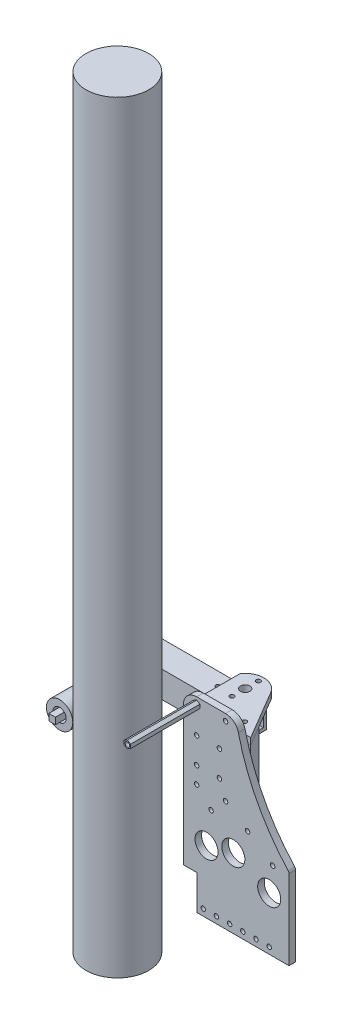
from build123d import *

# Parameters (mm, degrees)
ELEVATION_BAR_R            = 30.226
ELEVATION_BAR_PART_DEPTH   = 734.06
CLAMP_GEO_R                = 4.7625
CLAMP_GEO_W                = 6.35
CLAMP_GEO_H                = 12.7
CLAMP_GEO_R_2              = 1.8288
BOSS_EXTRUDE1_DEPTH        = 12.7
BOSS_EXTRUDE1_DEPTH_BACK   = 12.7
SKETCH2_W                  = 19.05
SKETCH2_H                  = 19.05
CUT_EXTRUDE2_DEPTH         = 105.590945
SKETCH3_R                  = 4.544009597
CUT_EXTRUDE3_DEPTH         = 25.4
CLAMP_GEO_3_W              = 6.35
CLAMP_GEO_3_H              = 81.75625
CLAMP_GEO_3_H_2            = 12.7
CLAMP_GEO_3_R              = 1.8288
BOSS_EXTRUDE2_DEPTH        = 3.175
BOSS_EXTRUDE2_DEPTH_BACK   = 3.175
CUSTOM_DRIVEN_FLYWHEEL_R   = 12.7
CUSTOM_DRIVEN_FLYWHEEL_R_2 = 6.35
BOSS_EXTRUDE3_DEPTH        = 12.7
BOSS_EXTRUDE3_DEPTH_BACK   = 25.4
SKETCH8_W                  = 12.7
SKETCH8_H                  = 18.542
SKETCH8_R                  = 1.8288
BOSS_EXTRUDE5_DEPTH        = 9.525
SKETCH10_W                 = 6.35
SKETCH10_H                 = 18.542
SKETCH10_R                 = 1.8288
CUT_EXTRUDE5_DEPTH         = 3.175
SKETCH17_R                 = 11.1125
SKETCH17_R_2               = 2.15265
BOSS_EXTRUDE6_DEPTH        = 6.35
SKETCH19_R                 = 2.15265
CUT_EXTRUDE6_DEPTH         = 36.5125
SKETCH23_R                 = 2.15265
SKETCH23_R_2               = 4.5466
BOSS_EXTRUDE7_DEPTH        = 6.35
SKETCH25_R                 = 2.15265
BOSS_EXTRUDE8_DEPTH        = 47.879
SKETCH26_R                 = 2.15265
CUT_EXTRUDE8_DEPTH         = 26.933555
SKETCH27_R                 = 2.15265
BOSS_EXTRUDE9_DEPTH        = 66.675
SKETCH28_R                 = 2.15265
BOSS_EXTRUDE10_DEPTH       = 4.8006
SKETCH31_R                 = 2.15265
CUT_EXTRUDE9_DEPTH         = 25.4
SKETCH33_R                 = 2.15265
CUT_EXTRUDE10_DEPTH        = 25.4


with BuildPart() as part:
    # Elevation Bar → Elevation Bar Part (new body)
    with BuildSketch(Plane(origin=(0, 0, 0), x_dir=(1, 0, 0), z_dir=(0, 1, 0))):
        Circle(ELEVATION_BAR_R)
    extrude(amount=ELEVATION_BAR_PART_DEPTH)


with BuildPart() as body_2:
    # Clamp Geo → Boss-Extrude1 (new body, two sides)
    with BuildSketch(Plane(origin=(0, 182.88, 0), x_dir=(1, 0, 0), z_dir=(0, 1, 0))) as boss_extrude1_sk:
        Polygon((39.751, 61.9125), (56.314945047, 61.9125), (56.314945047, 87.3125), (-39.751, 87.3125), (-39.751, 74.6125), (-39.751, 61.9125), (33.401, 61.9125), align=None)
        with Locations((48.377445047, 74.6125)):
            Circle(CLAMP_GEO_R, mode=Mode.SUBTRACT)
        Polygon((-46.101, 74.6125), (-46.101, 87.3125), (-49.276, 87.3125), (-49.276, 61.9125), (-46.101, 61.9125), align=None)
        with Locations((-42.926, 68.2625)):
            Rectangle(CLAMP_GEO_W, CLAMP_GEO_H)
        with Locations((-42.926, 68.2625)):
            Circle(CLAMP_GEO_R_2, mode=Mode.SUBTRACT)
        with Locations((-42.926, 80.9625)):
            Rectangle(CLAMP_GEO_W, CLAMP_GEO_H)
        with Locations((-42.926, 80.9625)):
            Circle(CLAMP_GEO_R_2, mode=Mode.SUBTRACT)
    extrude(amount=BOSS_EXTRUDE1_DEPTH)
    extrude(boss_extrude1_sk.sketch, amount=-BOSS_EXTRUDE1_DEPTH_BACK)

    # Sketch2 → Cut-Extrude2 (cut)
    with BuildSketch(Plane.ZY.offset(49.276)):
        with Locations((-74.6125, 182.88)):
            Rectangle(SKETCH2_W, SKETCH2_H)
    extrude(amount=-CUT_EXTRUDE2_DEPTH, mode=Mode.SUBTRACT)

    # Sketch3 → Cut-Extrude3 (cut)
    with BuildSketch(Plane(origin=(0, 0, -87.3125), x_dir=(-1, 0, 0), z_dir=(0, 0, -1))):
        with Locations((42.926, 182.88)):
            Circle(SKETCH3_R)
    extrude(amount=-CUT_EXTRUDE3_DEPTH, mode=Mode.SUBTRACT)

    # Sketch31 → Cut-Extrude9 (cut)
    with BuildSketch(Plane.XY.offset(-61.9125)):
        with Locations((36.576, 182.88)):
            Circle(SKETCH31_R)
    extrude(amount=-CUT_EXTRUDE9_DEPTH, mode=Mode.SUBTRACT)

    # Sketch33 → Cut-Extrude10 (cut)
    with BuildSketch(Plane.XZ.offset(-170.18)):
        with Locations((22.195724324, -74.6125)):
            Circle(SKETCH33_R)
    extrude(amount=-CUT_EXTRUDE10_DEPTH, mode=Mode.SUBTRACT)


with BuildPart() as body_3:
    # Clamp Geo_3 → Boss-Extrude2 (new body, two sides)
    with BuildSketch(Plane(origin=(0, 182.88, 0), x_dir=(1, 0, 0), z_dir=(0, 1, 0))) as boss_extrude2_sk:
        with Locations((-42.926, 21.034375)):
            Rectangle(CLAMP_GEO_3_W, CLAMP_GEO_3_H)
        with Locations((-42.926, 68.2625)):
            Rectangle(CLAMP_GEO_3_W, CLAMP_GEO_3_H_2)
        with Locations((-42.926, 68.2625)):
            Circle(CLAMP_GEO_3_R, mode=Mode.SUBTRACT)
        with Locations((-42.926, 80.9625)):
            Rectangle(CLAMP_GEO_3_W, CLAMP_GEO_3_H_2)
        with Locations((-42.926, 80.9625)):
            Circle(CLAMP_GEO_3_R, mode=Mode.SUBTRACT)
    extrude(amount=BOSS_EXTRUDE2_DEPTH)
    extrude(boss_extrude2_sk.sketch, amount=-BOSS_EXTRUDE2_DEPTH_BACK)


with BuildPart() as body_4:
    # Custom Driven Flywheel → Boss-Extrude3 (new body, two sides)
    with BuildSketch(Plane.XY) as boss_extrude3_sk:
        with Locations((-42.926, 182.88)):
            Circle(CUSTOM_DRIVEN_FLYWHEEL_R)
        with Locations((-42.926, 182.88)):
            Circle(CUSTOM_DRIVEN_FLYWHEEL_R_2, mode=Mode.SUBTRACT)
    extrude(amount=BOSS_EXTRUDE3_DEPTH)
    extrude(boss_extrude3_sk.sketch, amount=-BOSS_EXTRUDE3_DEPTH_BACK)


with BuildPart() as body_5:
    # Sketch8 → Boss-Extrude5 (new body)
    with BuildSketch(Plane(origin=(0, 173.355, 0), x_dir=(1, 0, 0), z_dir=(0, 1, 0))):
        with Locations((-42.926, 74.6125)):
            Rectangle(SKETCH8_W, SKETCH8_H)
        with Locations((-42.926, 80.9625)):
            Circle(SKETCH8_R, mode=Mode.SUBTRACT)
        with Locations((-42.926, 68.2625)):
            Circle(SKETCH8_R, mode=Mode.SUBTRACT)
    extrude(amount=BOSS_EXTRUDE5_DEPTH)

    # Sketch10 → Cut-Extrude5 (cut)
    with BuildSketch(Plane(origin=(0, 182.88, 0), x_dir=(1, 0, 0), z_dir=(0, 1, 0))):
        with Locations((-42.926, 74.6125)):
            Rectangle(SKETCH10_W, SKETCH10_H)
        with Locations((-42.926, 68.2625)):
            Circle(SKETCH10_R, mode=Mode.SUBTRACT)
        with Locations((-42.926, 80.9625)):
            Circle(SKETCH10_R, mode=Mode.SUBTRACT)
    extrude(amount=-CUT_EXTRUDE5_DEPTH, mode=Mode.SUBTRACT)


with BuildPart() as body_6:
    # Sketch17 → Boss-Extrude6 (new body)
    with BuildSketch(Plane.XY.offset(-36.5125)):
        with BuildLine():
            Line((135.001, 118.017245545), (135.001, 73.152))
            Line((135.001, 73.152), (135.001, 41.275))
            Line((135.001, 41.275), (46.355, 41.275))
            Line((46.355, 41.275), (46.355, 74.6125))
            Line((46.355, 74.6125), (33.401, 74.6125))
            Line((33.401, 74.6125), (33.401, 208.28))
            ThreePointArc((33.401, 208.28), (37.120743879, 217.260256121), (46.101, 220.98))
            Line((46.101, 220.98), (73.935512876, 220.98))
            ThreePointArc((73.935512876, 220.98), (81.833694908, 218.22528635), (86.30554153, 211.156176471))
            ThreePointArc((86.30554153, 211.156176471), (104.387300681, 162.579639504), (134.170615385, 120.158134075))
            ThreePointArc((134.170615385, 120.158134075), (134.786133345, 119.165389951), (135.001, 118.017245545))
        make_face()
        with Locations((55.626, 101.727)):
            Circle(SKETCH17_R, mode=Mode.SUBTRACT)
        with Locations((81.409159883, 108.54737876)):
            Circle(SKETCH17_R, mode=Mode.SUBTRACT)
        with Locations((115.951, 92.470336702)):
            Circle(SKETCH17_R, mode=Mode.SUBTRACT)
        with Locations((46.101, 214.63)):
            Circle(SKETCH17_R_2, mode=Mode.SUBTRACT)
        with Locations((73.935512876, 214.63)):
            Circle(SKETCH17_R_2, mode=Mode.SUBTRACT)
        with Locations((119.286745244, 116.882770029)):
            Circle(SKETCH17_R_2, mode=Mode.SUBTRACT)
        with Locations((46.101, 147.955)):
            Circle(SKETCH17_R_2, mode=Mode.SUBTRACT)
        with Locations((73.935512876, 147.955)):
            Circle(SKETCH17_R_2, mode=Mode.SUBTRACT)
        with Locations((60.018256438, 133.455471594)):
            Circle(SKETCH17_R_2, mode=Mode.SUBTRACT)
        with Locations((95.098187154, 133.455471594)):
            Circle(SKETCH17_R_2, mode=Mode.SUBTRACT)
    extrude(amount=BOSS_EXTRUDE6_DEPTH)

    # Sketch19 → Cut-Extrude6 (cut)
    with BuildSketch(Plane.XY):
        with Locations((39.751, 47.625)):
            Circle(SKETCH19_R)
        with Locations((52.451, 47.625)):
            Circle(SKETCH19_R)
        with Locations((65.151, 47.625)):
            Circle(SKETCH19_R)
        with Locations((77.851, 47.625)):
            Circle(SKETCH19_R)
        with Locations((90.551, 47.625)):
            Circle(SKETCH19_R)
        with Locations((103.251, 47.625)):
            Circle(SKETCH19_R)
        with Locations((115.951, 47.625)):
            Circle(SKETCH19_R)
    extrude(amount=-CUT_EXTRUDE6_DEPTH, mode=Mode.SUBTRACT)


with BuildPart() as body_7:
    # Sketch23 → Boss-Extrude7 (new body)
    with BuildSketch(Plane(origin=(0, 200.3425, 0), x_dir=(1, 0, 0), z_dir=(0, 1, 0))):
        with BuildLine():
            ThreePointArc((63.899351564, 83.78128305), (57.983234825, 59.357174134), (33.401, 64.577448517))
            Line((33.401, 64.577448517), (33.401, 36.5125))
            Line((33.401, 36.5125), (91.821, 36.5125))
            Line((91.821, 36.5125), (63.899351564, 83.78128305))
        make_face()
        with Locations((56.531651772, 46.804277476)):
            Circle(SKETCH23_R, mode=Mode.SUBTRACT)
        with Locations((75.581651772, 46.804277476)):
            Circle(SKETCH23_R, mode=Mode.SUBTRACT)
        with BuildLine():
            ThreePointArc((63.899351564, 83.78128305), (48.889292, 92.632882272), (33.401, 84.647551483))
            Line((33.401, 84.647551483), (33.401, 64.577448517))
            ThreePointArc((33.401, 64.577448517), (57.983234825, 59.357174134), (63.899351564, 83.78128305))
        make_face()
        with Locations((48.377445047, 61.9125)):
            Circle(SKETCH23_R, mode=Mode.SUBTRACT)
        with Locations((48.377445047, 74.6125)):
            Circle(SKETCH23_R_2, mode=Mode.SUBTRACT)
        with Locations((48.377445047, 87.3125)):
            Circle(SKETCH23_R, mode=Mode.SUBTRACT)
    extrude(amount=BOSS_EXTRUDE7_DEPTH)


with BuildPart() as body_8:
    # Sketch25 → Boss-Extrude8 (new body)
    with BuildSketch(Plane.XZ.offset(-200.3425)):
        with BuildLine():
            Line((91.821, -36.5125), (80.399595356, -55.847887718))
            ThreePointArc((80.399595356, -55.847887718), (79.471677579, -56.762053052), (78.212641285, -57.096054953))
            Line((78.212641285, -57.096054953), (35.941, -57.096054953))
            ThreePointArc((35.941, -57.096054953), (34.144948776, -56.352106177), (33.401, -54.556054953))
            Line((33.401, -54.556054953), (33.401, -36.5125))
            Line((33.401, -36.5125), (91.821, -36.5125))
        make_face()
        with Locations((56.531651772, -46.804277476)):
            Circle(SKETCH25_R, mode=Mode.SUBTRACT)
        with Locations((75.581651772, -46.804277476)):
            Circle(SKETCH25_R, mode=Mode.SUBTRACT)
    extrude(amount=BOSS_EXTRUDE8_DEPTH)


with BuildPart() as cut_extrude8_tool:
    # Sketch26 → Cut-Extrude8 (new body)
    with BuildSketch(Plane(origin=(0, 0, -57.096054953), x_dir=(-1, 0, 0), z_dir=(0, 0, -1))):
        with Locations((-68.052641285, 188.834769872)):
            Circle(SKETCH26_R)
        with Locations((-68.052641285, 163.971230128)):
            Circle(SKETCH26_R)
        with Locations((-46.101, 163.971230128)):
            Circle(SKETCH26_R)
        with Locations((-46.101, 188.834769872)):
            Circle(SKETCH26_R)
    extrude(amount=-CUT_EXTRUDE8_DEPTH)


with BuildPart() as body_6_1:
    add(body_6.part)

    # Cut-Extrude8: cut by cut_extrude8_tool
    add(cut_extrude8_tool.part, mode=Mode.SUBTRACT)


with BuildPart() as body_8_1:
    add(body_8.part)

    # Cut-Extrude8: cut by cut_extrude8_tool
    add(cut_extrude8_tool.part, mode=Mode.SUBTRACT)


with BuildPart() as body_9:
    # Sketch27 → Boss-Extrude9 (new body)
    with BuildSketch(Plane.XY.offset(-30.1625)):
        Polygon((42.926, 216.463087105), (42.926, 212.796912895), (46.101, 210.963825791), (49.276, 212.796912895), (49.276, 216.463087105), (46.101, 218.296174209), align=None)
        with Locations((46.101, 214.63)):
            Circle(SKETCH27_R, mode=Mode.SUBTRACT)
    extrude(amount=BOSS_EXTRUDE9_DEPTH)


with BuildPart() as body_10:
    # Sketch28 → Boss-Extrude10 (new body)
    with BuildSketch(Plane.XY.offset(-61.9125)):
        Polygon((33.401, 184.713087105), (33.401, 181.046912895), (36.576, 179.213825791), (39.751, 181.046912895), (39.751, 184.713087105), (36.576, 186.546174209), align=None)
        with Locations((36.576, 182.88)):
            Circle(SKETCH28_R, mode=Mode.SUBTRACT)
    extrude(amount=BOSS_EXTRUDE10_DEPTH)


solid = Compound([part.part, body_2.part, body_3.part, body_4.part, body_5.part, body_7.part, body_6_1.part, body_8_1.part, body_9.part, body_10.part])
